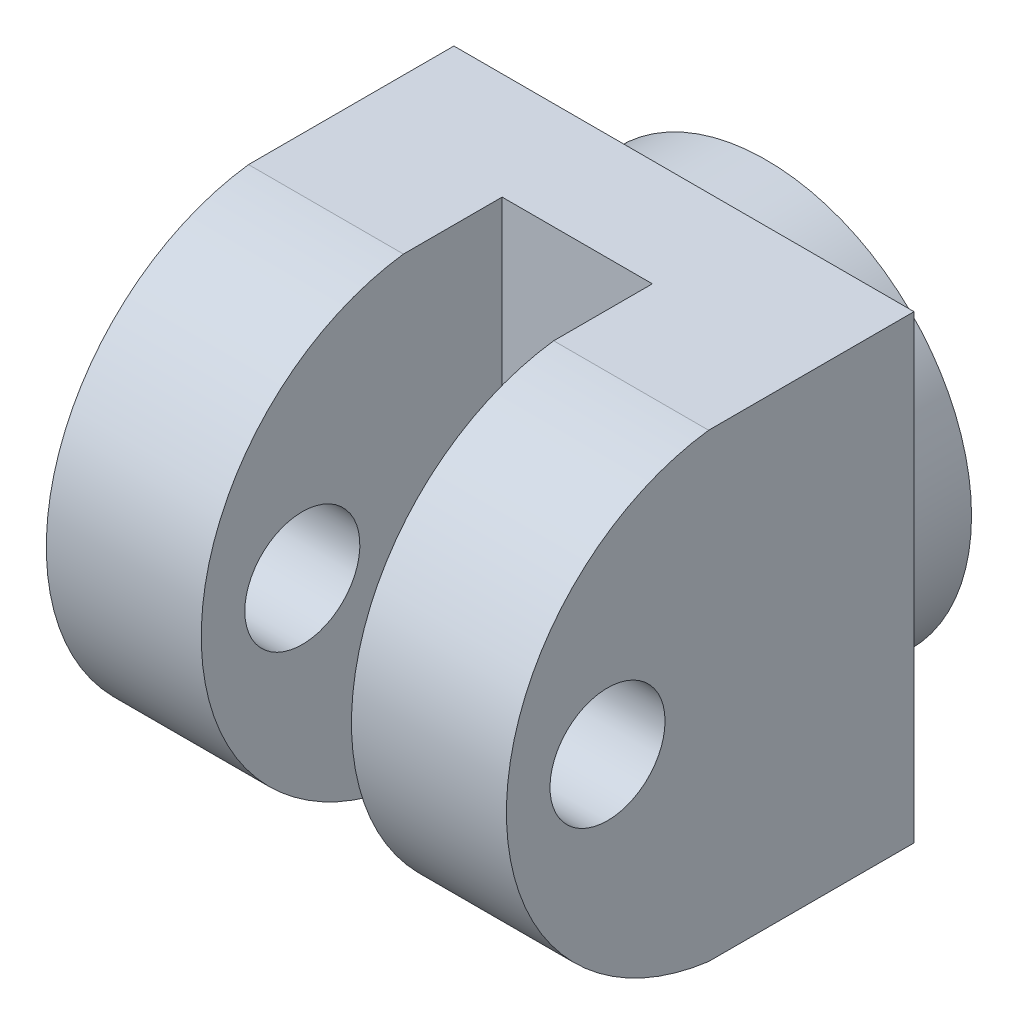
from build123d import *

# Parameters (mm, degrees)
SKETCH1_R               = 12.5
SKETCH1_R_2             = 10
BOSS_EXTRUDE1_DEPTH     = 5
SKETCH2_W               = 28
SKETCH2_H               = 28
BOSS_EXTRUDE2_DEPTH     = 25
CUT_EXTRUDE1_DEPTH      = 29
SKETCH7_W               = 9.14199999
SKETCH7_H               = 19.416637146
CUT_EXTRUDE2_DEPTH      = 1
CUT_EXTRUDE2_DEPTH_BACK = 29
SKETCH8_R               = 3.5
CUT_EXTRUDE3_DEPTH      = 1
CUT_EXTRUDE3_DEPTH_BACK = 29


with BuildPart() as part:
    # Sketch1 → Boss-Extrude1 (new body)
    with BuildSketch(Plane.XY):
        Circle(SKETCH1_R)
        Circle(SKETCH1_R_2, mode=Mode.SUBTRACT)
    extrude(amount=BOSS_EXTRUDE1_DEPTH)

    # Sketch2 → Boss-Extrude2 (add)
    with BuildSketch(Plane.XY.offset(5)):
        Rectangle(SKETCH2_W, SKETCH2_H)
    extrude(amount=BOSS_EXTRUDE2_DEPTH)

    # Sketch3 → Cut-Extrude1 (cut, through all)
    with BuildSketch(Plane.ZY.offset(14)):
        with BuildLine():
            Line((17.5, 14), (30, 14))
            Line((30, 14), (30, -14))
            Line((30, -14), (17.5, -14))
            ThreePointArc((17.5, -14), (29.804652609, 0), (17.5, 14))
        make_face()
    extrude(amount=-CUT_EXTRUDE1_DEPTH, mode=Mode.SUBTRACT)

    # Sketch7 → Cut-Extrude2 (cut, two sides)
    with BuildSketch(Plane.XZ.offset(14)) as cut_extrude2_sk:
        with Locations((0, 21.203451283)):
            Rectangle(SKETCH7_W, SKETCH7_H)
    extrude(amount=CUT_EXTRUDE2_DEPTH, mode=Mode.SUBTRACT)
    extrude(cut_extrude2_sk.sketch, amount=-CUT_EXTRUDE2_DEPTH_BACK, mode=Mode.SUBTRACT)

    # Sketch8 → Cut-Extrude3 (cut, two sides)
    with BuildSketch(Plane(origin=(14, 0, 0), x_dir=(0, 0, -1), z_dir=(1, 0, 0))) as cut_extrude3_sk:
        with Locations((-23.652326304, 0)):
            Circle(SKETCH8_R)
    extrude(amount=CUT_EXTRUDE3_DEPTH, mode=Mode.SUBTRACT)
    extrude(cut_extrude3_sk.sketch, amount=-CUT_EXTRUDE3_DEPTH_BACK, mode=Mode.SUBTRACT)


solid = part.part
